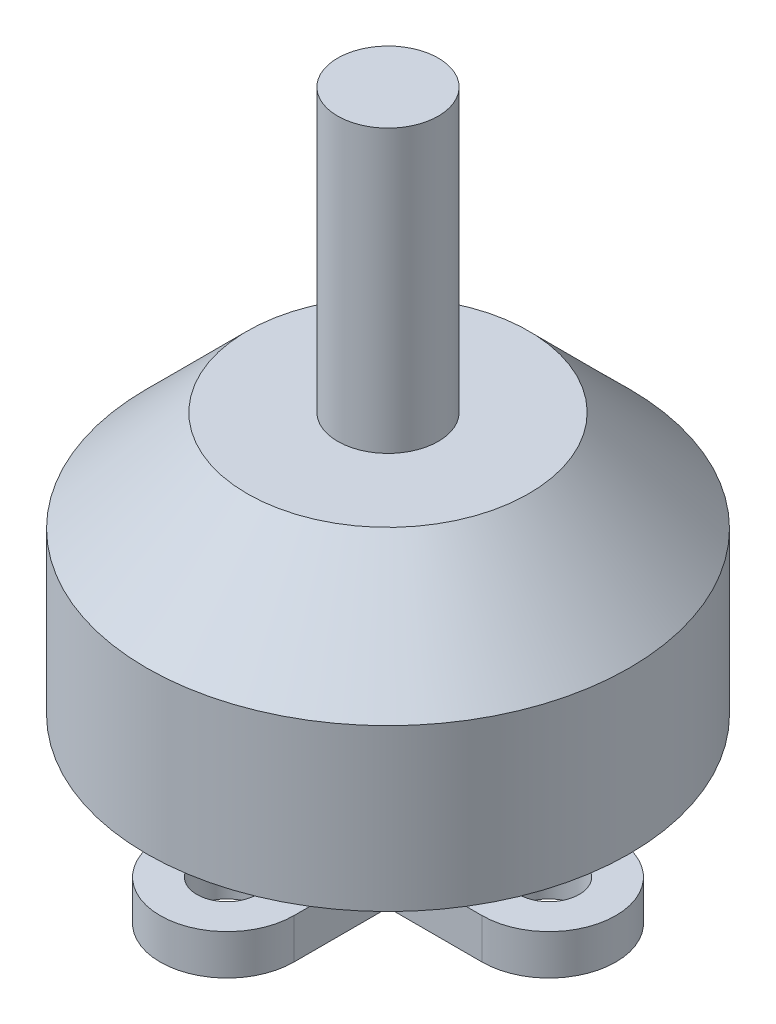
from build123d import *

# Parameters (mm, degrees)
SKETCH_1_R      = 1.5
EXTRUDE_1_DEPTH = 2
SKETCH_2_R      = 4.695496225
EXTRUDE_2_DEPTH = 3
SKETCH_3_R      = 12
EXTRUDE_3_DEPTH = 13
CHAMFER_1_SIZE  = 5
SKETCH_4_R      = 2.5
EXTRUDE_4_DEPTH = 14


with BuildPart() as part:
    # 草图1 → 凸台-拉伸1 (new body)
    with BuildSketch(Plane(origin=(0, 0, 0), x_dir=(1, 0, 0), z_dir=(0, 1, 0))):
        with BuildLine():
            Line((-3.320217222, -4.320217222), (-3.320217222, -8))
            ThreePointArc((-3.320217222, -8), (0, -11.320217222), (3.320217222, -8))
            Line((3.320217222, -8), (3.320217222, -4.320217222))
            Line((3.320217222, -4.320217222), (3.320217222, -3.320217222))
            Line((3.320217222, -3.320217222), (4.320217222, -3.320217222))
            Line((4.320217222, -3.320217222), (8, -3.320217222))
            ThreePointArc((8, -3.320217222), (11.320217222, 0), (8, 3.320217222))
            Line((8, 3.320217222), (4.320217222, 3.320217222))
            Line((4.320217222, 3.320217222), (3.320217222, 3.320217222))
            Line((3.320217222, 3.320217222), (3.320217222, 4.320217222))
            Line((3.320217222, 4.320217222), (3.320217222, 8))
            ThreePointArc((3.320217222, 8), (0, 11.320217222), (-3.320217222, 8))
            Line((-3.320217222, 8), (-3.320217222, 4.320217222))
            Line((-3.320217222, 4.320217222), (-3.320217222, 3.320217222))
            Line((-3.320217222, 3.320217222), (-4.320217222, 3.320217222))
            Line((-4.320217222, 3.320217222), (-8, 3.320217222))
            ThreePointArc((-8, 3.320217222), (-11.320217222, 0), (-8, -3.320217222))
            Line((-8, -3.320217222), (-4.320217222, -3.320217222))
            Line((-4.320217222, -3.320217222), (-3.320217222, -3.320217222))
            Line((-3.320217222, -3.320217222), (-3.320217222, -4.320217222))
        make_face()
        with Locations((0, -8)):
            Circle(SKETCH_1_R, mode=Mode.SUBTRACT)
        with Locations((8, 0)):
            Circle(SKETCH_1_R, mode=Mode.SUBTRACT)
        with Locations((-8, 0)):
            Circle(SKETCH_1_R, mode=Mode.SUBTRACT)
        with Locations((0, 8)):
            Circle(SKETCH_1_R, mode=Mode.SUBTRACT)
    extrude(amount=EXTRUDE_1_DEPTH)

    # 草图2 → 凸台-拉伸2 (add)
    with BuildSketch(Plane(origin=(0, 2, 0), x_dir=(1, 0, 0), z_dir=(0, 1, 0))):
        Circle(SKETCH_2_R)
    extrude(amount=EXTRUDE_2_DEPTH)

    # 草图3 → 凸台-拉伸3 (add)
    with BuildSketch(Plane(origin=(0, 5, 0), x_dir=(1, 0, 0), z_dir=(0, 1, 0))):
        Circle(SKETCH_3_R)
    extrude(amount=EXTRUDE_3_DEPTH)

    # 倒角1
    chamfer_1_edges = [part.edges().sort_by_distance(p)[0] for p in [
        (-12, 18, 0),
    ]]
    chamfer(chamfer_1_edges, length=CHAMFER_1_SIZE)

    # 草图4 → 凸台-拉伸4 (add)
    with BuildSketch(Plane(origin=(0, 18, 0), x_dir=(1, 0, 0), z_dir=(0, 1, 0))):
        Circle(SKETCH_4_R)
    extrude(amount=EXTRUDE_4_DEPTH)


solid = part.part
